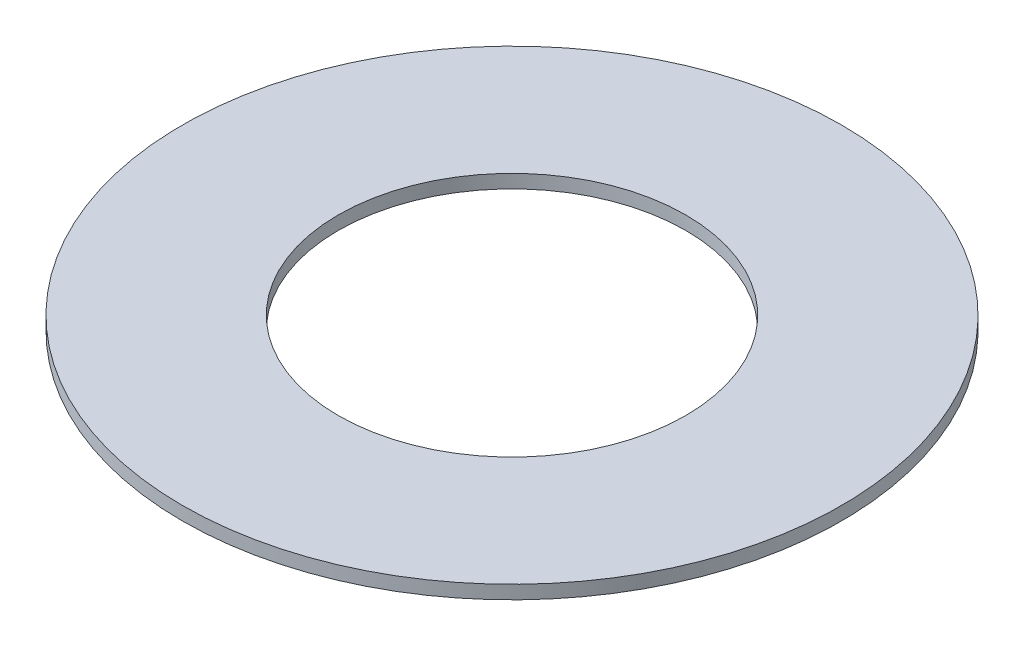
from build123d import *

# Parameters (mm, degrees)
SKETCH1_R           = 22
SKETCH1_R_2         = 11.6
BOSS_EXTRUDE1_DEPTH = 0.9


with BuildPart() as part:
    # Sketch1 → Boss-Extrude1 (new body)
    with BuildSketch(Plane(origin=(0, 0, 0), x_dir=(1, 0, 0), z_dir=(0, 1, 0))):
        Circle(SKETCH1_R)
        Circle(SKETCH1_R_2, mode=Mode.SUBTRACT)
    extrude(amount=BOSS_EXTRUDE1_DEPTH)


solid = part.part
